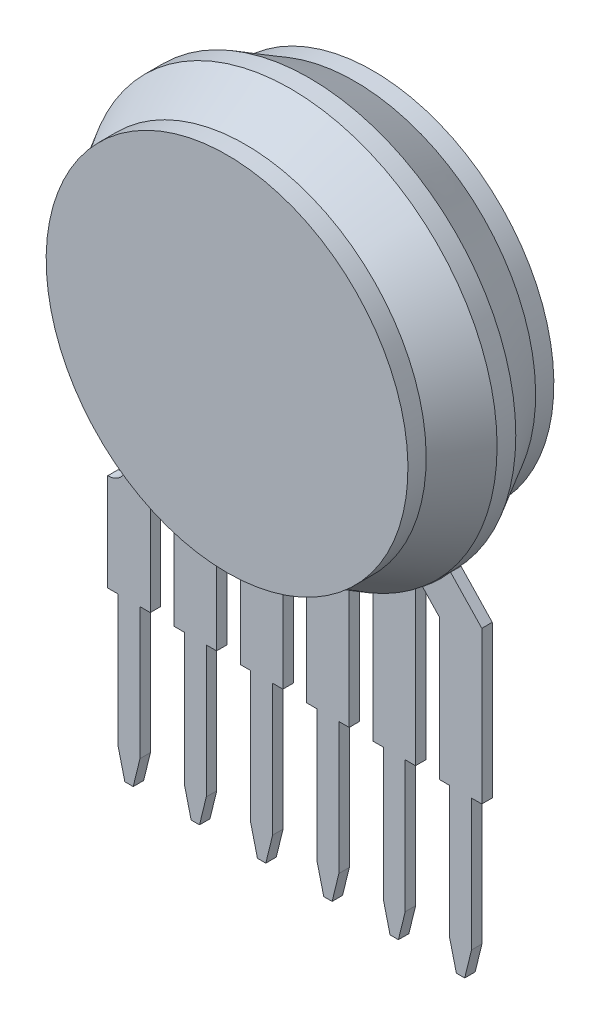
from build123d import *

# Parameters (mm, degrees)
EXTRUDE6_DEPTH        = 0.2
EXTRUDE6_DEPTH_BACK   = 0.2
EXTRUDE6_2_DEPTH      = 0.2
EXTRUDE6_2_DEPTH_BACK = 0.2
EXTRUDE6_3_DEPTH      = 0.2
EXTRUDE6_3_DEPTH_BACK = 0.2
EXTRUDE6_4_DEPTH      = 0.2
EXTRUDE6_4_DEPTH_BACK = 0.2
EXTRUDE6_5_DEPTH      = 0.2
EXTRUDE6_5_DEPTH_BACK = 0.2
EXTRUDE6_6_DEPTH      = 0.2
EXTRUDE6_6_DEPTH_BACK = 0.2


with BuildPart() as part:
    # Sketch7 → Extrude6 (new body, two sides)
    with BuildSketch(Plane.XY) as extrude6_sk:
        with BuildLine():
            Line((-5.93, -12.32), (-5.535, -12.32))
            Line((-5.535, -12.32), (-5.535, -6.923244628))
            Line((-5.535, -6.923244628), (-4.893151867, -6.24528278))
            ThreePointArc((-4.893151867, -6.24528278), (-5.454552369, -5.761453866), (-5.968357327, -5.227351434))
            Line((-5.968357327, -5.227351434), (-7.165, -6.49132345))
            Line((-7.165, -6.49132345), (-7.165, -7.17281133))
            ThreePointArc((-7.165, -7.17281133), (-6.454703172, -7.883108158), (-7.165, -8.593404986))
            Line((-7.165, -8.593404986), (-7.165, -12.32))
            Line((-7.165, -12.32), (-6.77, -12.32))
            Line((-6.77, -12.32), (-6.77, -17.360738904))
            Line((-6.77, -17.360738904), (-6.510329667, -18.42))
            Line((-6.510329667, -18.42), (-6.189670333, -18.42))
            Line((-6.189670333, -18.42), (-5.93, -17.360738904))
            Line((-5.93, -17.360738904), (-5.93, -12.32))
        make_face()
    extrude(amount=EXTRUDE6_DEPTH)
    extrude(extrude6_sk.sketch, amount=-EXTRUDE6_DEPTH_BACK)


with BuildPart() as body_2:
    # Sketch7 → Extrude6 2 (new body, two sides)
    with BuildSketch(Plane.XY) as extrude6_2_sk:
        with BuildLine():
            Line((-4.625, -6.446384041), (-4.625, -12.32))
            Line((-4.625, -12.32), (-4.23, -12.32))
            Line((-4.23, -12.32), (-4.23, -17.360738904))
            Line((-4.23, -17.360738904), (-3.970329667, -18.42))
            Line((-3.970329667, -18.42), (-3.649670333, -18.42))
            Line((-3.649670333, -18.42), (-3.39, -17.360738904))
            Line((-3.39, -17.360738904), (-3.39, -12.32))
            Line((-3.39, -12.32), (-2.995, -12.32))
            Line((-2.995, -12.32), (-2.995, -7.34686785))
            ThreePointArc((-2.995, -7.34686785), (-3.836511146, -6.944614779), (-4.625, -6.446384041))
        make_face()
    extrude(amount=EXTRUDE6_2_DEPTH)
    extrude(extrude6_2_sk.sketch, amount=-EXTRUDE6_2_DEPTH_BACK)


with BuildPart() as body_3:
    # Sketch7 → Extrude6 3 (new body, two sides)
    with BuildSketch(Plane.XY) as extrude6_3_sk:
        with BuildLine():
            Line((-0.455, -12.32), (-0.455, -7.920824907))
            ThreePointArc((-0.455, -7.920824907), (-1.276935244, -7.830448811), (-2.085, -7.65501582))
            Line((-2.085, -7.65501582), (-2.085, -12.32))
            Line((-2.085, -12.32), (-1.69, -12.32))
            Line((-1.69, -12.32), (-1.69, -17.360738904))
            Line((-1.69, -17.360738904), (-1.430329667, -18.42))
            Line((-1.430329667, -18.42), (-1.109670333, -18.42))
            Line((-1.109670333, -18.42), (-0.85, -17.360738904))
            Line((-0.85, -17.360738904), (-0.85, -12.32))
            Line((-0.85, -12.32), (-0.455, -12.32))
        make_face()
    extrude(amount=EXTRUDE6_3_DEPTH)
    extrude(extrude6_3_sk.sketch, amount=-EXTRUDE6_3_DEPTH_BACK)


with BuildPart() as body_4:
    # Sketch7 → Extrude6 4 (new body, two sides)
    with BuildSketch(Plane.XY) as extrude6_4_sk:
        with BuildLine():
            Line((4.625, -12.32), (4.625, -6.446384041))
            ThreePointArc((4.625, -6.446384041), (3.836511146, -6.944614779), (2.995, -7.34686785))
            Line((2.995, -7.34686785), (2.995, -12.32))
            Line((2.995, -12.32), (3.39, -12.32))
            Line((3.39, -12.32), (3.39, -17.360738904))
            Line((3.39, -17.360738904), (3.649670333, -18.42))
            Line((3.649670333, -18.42), (3.970329667, -18.42))
            Line((3.970329667, -18.42), (4.23, -17.360738904))
            Line((4.23, -17.360738904), (4.23, -12.32))
            Line((4.23, -12.32), (4.625, -12.32))
        make_face()
    extrude(amount=EXTRUDE6_4_DEPTH)
    extrude(extrude6_4_sk.sketch, amount=-EXTRUDE6_4_DEPTH_BACK)


with BuildPart() as body_5:
    # Sketch7 → Extrude6 5 (new body, two sides)
    with BuildSketch(Plane.XY) as extrude6_5_sk:
        with BuildLine():
            Line((0.455, -7.920824907), (0.455, -12.32))
            Line((0.455, -12.32), (0.85, -12.32))
            Line((0.85, -12.32), (0.85, -17.360738904))
            Line((0.85, -17.360738904), (1.109670333, -18.42))
            Line((1.109670333, -18.42), (1.430329667, -18.42))
            Line((1.430329667, -18.42), (1.69, -17.360738904))
            Line((1.69, -17.360738904), (1.69, -12.32))
            Line((1.69, -12.32), (2.085, -12.32))
            Line((2.085, -12.32), (2.085, -7.65501582))
            ThreePointArc((2.085, -7.65501582), (1.276935244, -7.830448811), (0.455, -7.920824907))
        make_face()
    extrude(amount=EXTRUDE6_5_DEPTH)
    extrude(extrude6_5_sk.sketch, amount=-EXTRUDE6_5_DEPTH_BACK)


with BuildPart() as body_6:
    # Sketch7 → Extrude6 6 (new body, two sides)
    with BuildSketch(Plane.XY) as extrude6_6_sk:
        with BuildLine():
            Line((5.535, -12.32), (5.93, -12.32))
            Line((5.93, -12.32), (5.93, -17.360738904))
            Line((5.93, -17.360738904), (6.189670333, -18.42))
            Line((6.189670333, -18.42), (6.510329667, -18.42))
            Line((6.510329667, -18.42), (6.77, -17.360738904))
            Line((6.77, -17.360738904), (6.77, -12.32))
            Line((6.77, -12.32), (7.165, -12.32))
            Line((7.165, -12.32), (7.165, -6.49132345))
            Line((7.165, -6.49132345), (5.968357327, -5.227351434))
            ThreePointArc((5.968357327, -5.227351434), (5.454552369, -5.761453866), (4.893151867, -6.24528278))
            Line((4.893151867, -6.24528278), (5.535, -6.923244628))
            Line((5.535, -6.923244628), (5.535, -12.32))
        make_face()
    extrude(amount=EXTRUDE6_6_DEPTH)
    extrude(extrude6_6_sk.sketch, amount=-EXTRUDE6_6_DEPTH_BACK)


with BuildPart() as body_7:
    # Sketch8 → Revolve1 (revolve)
    with BuildSketch(Plane(origin=(0, 0, 0), x_dir=(0, 0, -1), z_dir=(1, 0, 0))):
        Polygon((2.795, 0), (2.795, 6.93), (2.096257799, 6.93), (0.358195537, 7.908398157), (-0.358195537, 7.908398157), (-2.096257799, 6.93), (-2.795, 6.93), (-2.795, 0), align=None)
    revolve(axis=Axis((0, 0, -2.795), (0, 0, -1)))


solid = Compound([part.part, body_2.part, body_3.part, body_4.part, body_5.part, body_6.part, body_7.part])
